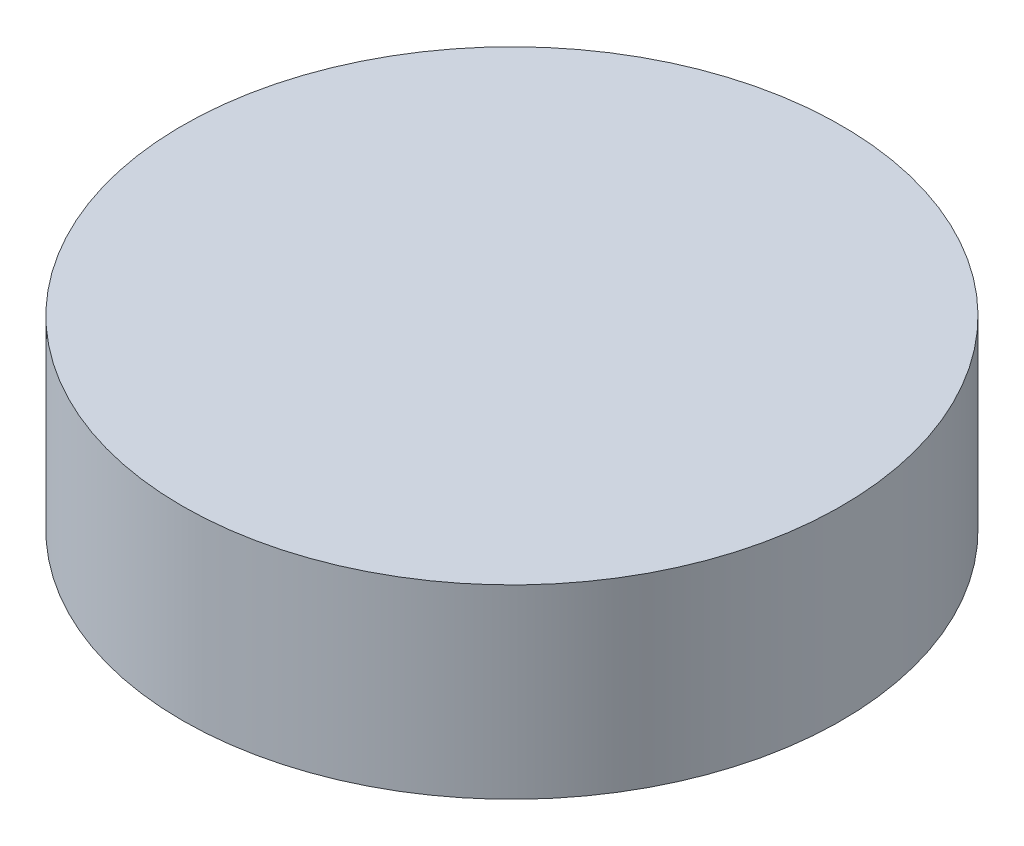
from build123d import *

# Parameters (mm, degrees)
SKIZZE1_R                       = 8.875
AUFSATZ_LINEAR_AUSTRAGEN1_DEPTH = 5


with BuildPart() as part:
    # Skizze1 → Aufsatz-Linear austragen1 (new body)
    with BuildSketch(Plane(origin=(0, 0, 0), x_dir=(1, 0, 0), z_dir=(0, 1, 0))):
        Circle(SKIZZE1_R)
    extrude(amount=AUFSATZ_LINEAR_AUSTRAGEN1_DEPTH)


solid = part.part
